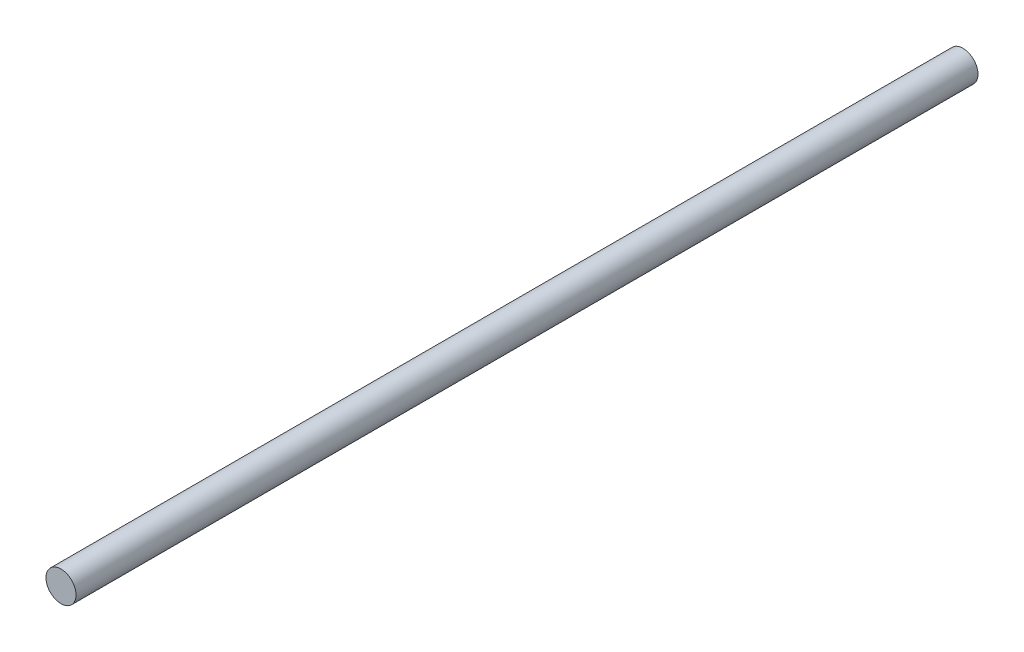
from build123d import *

# Parameters (mm, degrees)
IZIM1_R                     = 4
Y_KSEKLIK_EKSTR_ZYON1_DEPTH = 240


with BuildPart() as part:
    # Çizim1 → Yükseklik-Ekstrüzyon1 (new body)
    with BuildSketch(Plane.XY):
        Circle(IZIM1_R)
    extrude(amount=Y_KSEKLIK_EKSTR_ZYON1_DEPTH)


solid = part.part
